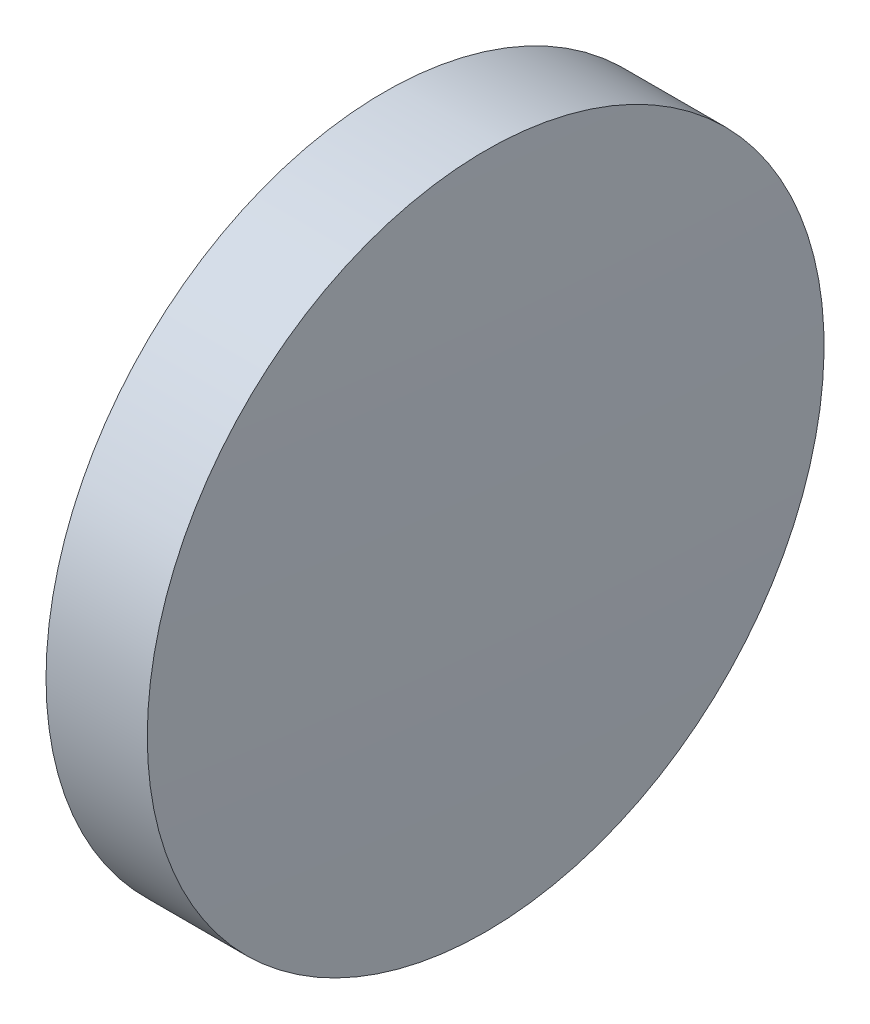
from build123d import *


with BuildPart() as part:
    # 草图1 → 旋转1 (revolve)
    with BuildSketch(Plane.XY, mode=Mode.PRIVATE) as revolve_1_sk:
        with BuildLine():
            Line((487.712507803, 125.178527759), (487.712507803, 137.878527759))
            Line((487.712507803, 137.878527759), (491.512507803, 137.878527759))
            ThreePointArc((491.512507803, 137.878527759), (491.662504703, 131.529315111), (491.712507803, 125.178527759))
            Line((491.712507803, 125.178527759), (487.712507803, 125.178527759))
        make_face()
    revolve(revolve_1_sk.sketch.rotate(Axis((482.082611751, 125.178527759, 0), (1, 0, 0)), 180), axis=Axis((482.082611751, 125.178527759, 0), (1, 0, 0)))  # turned: the seam where the file's is


solid = part.part
